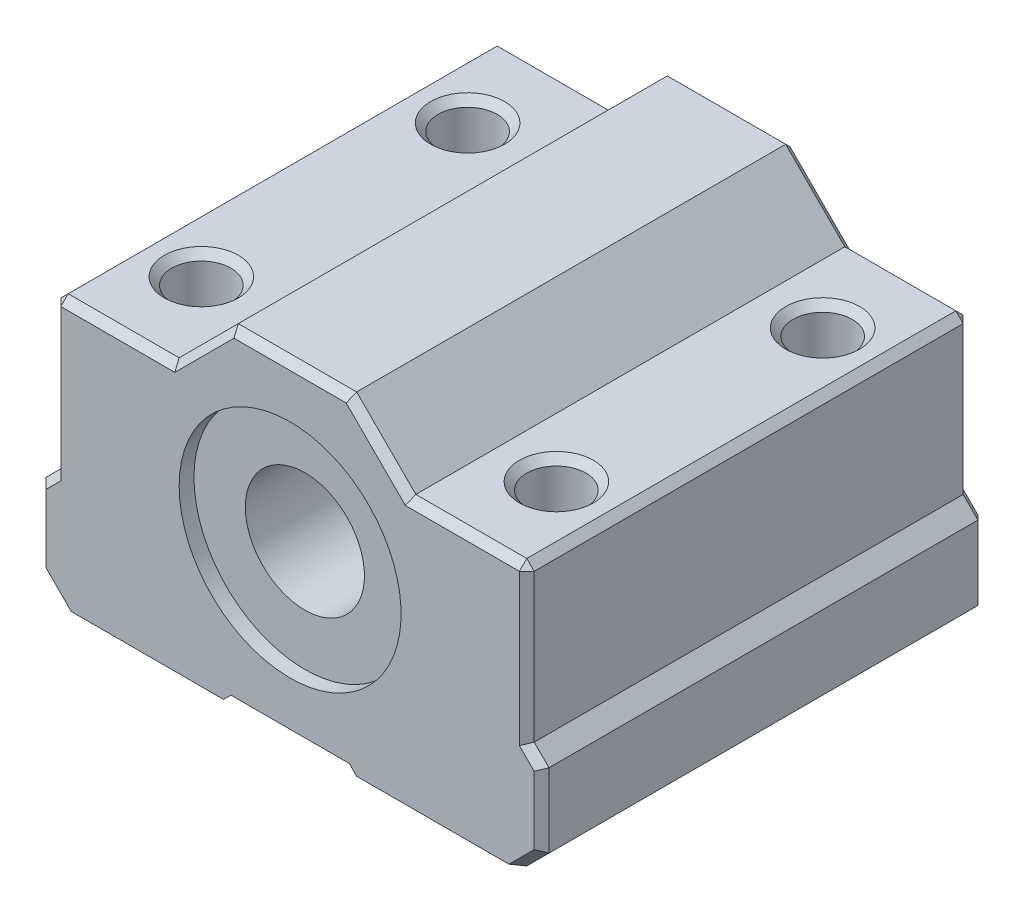
from build123d import *

# Parameters (mm, degrees)
ESBO_O1_W                      = 34
ESBO_O1_H                      = 30
RESSALTO_EXTRUS_O1_DEPTH       = 22
CORTE_EXTRUS_O1_DEPTH          = 31
CORTE_EXTRUS_O2_DEPTH          = 31
CORTE_EXTRUS_O3_DEPTH          = 31
CORTE_EXTRUS_O4_DEPTH          = 31
CORTE_EXTRUS_O5_DEPTH          = 31
FURO_DE_DI_METRO_4_0_4_1_D     = 4
FURO_DE_DI_METRO_4_0_4_1_DEPTH = 18
FURO_DE_DI_METRO_4_0_4_2_D     = 4
FURO_DE_DI_METRO_4_0_4_2_DEPTH = 22
CHANFRO1_SIZE                  = 1.5
CHANFRO2_SIZE                  = 0.500000009


with BuildPart() as part:
    # Esboço1 → Ressalto-extrusão1 (new body)
    with BuildSketch(Plane(origin=(0, 13.318571188, 0), x_dir=(1, 0, 0), z_dir=(0, 1, 0))):
        with Locations((0.093581821, -15)):
            Rectangle(ESBO_O1_W, ESBO_O1_H)
    extrude(amount=-RESSALTO_EXTRUS_O1_DEPTH)

    # Esboço2 → Corte-extrusão1 (cut, through all)
    with BuildSketch(Plane(origin=(0, 0, 0), x_dir=(-1, 0, 0), z_dir=(0, 0, -1))):
        Polygon((-17.093581821, -2.181428812), (-16.093581821, -1.181428812), (-16.093581821, 13.318571188), (-17.093581821, 13.318571188), align=None)
    extrude(amount=-CORTE_EXTRUS_O1_DEPTH, mode=Mode.SUBTRACT)

    # Esboço3 → Corte-extrusão2 (cut, through all)
    with BuildSketch(Plane(origin=(0, 0, 0), x_dir=(-1, 0, 0), z_dir=(0, 0, -1))):
        Polygon((-16.093581821, 13.318571188), (-16.093581821, 9.318571188), (-8.093581821, 9.318571188), (-4.093581821, 13.318571188), align=None)
    extrude(amount=-CORTE_EXTRUS_O2_DEPTH, mode=Mode.SUBTRACT)

    # Esboço4 → Corte-extrusão3 (cut, through all)
    with BuildSketch(Plane(origin=(0, 0, 0), x_dir=(-1, 0, 0), z_dir=(0, 0, -1))):
        Polygon((16.906418179, 13.318571188), (3.906418179, 13.318571188), (7.906418179, 9.318571188), (16.906418179, 9.318571188), align=None)
    extrude(amount=-CORTE_EXTRUS_O3_DEPTH, mode=Mode.SUBTRACT)

    # Esboço5 → Corte-extrusão4 (cut, through all)
    with BuildSketch(Plane(origin=(0, 0, 0), x_dir=(-1, 0, 0), z_dir=(0, 0, -1))):
        Polygon((15.906418179, 9.318571188), (15.906418179, -1.181428812), (16.906418179, -2.181428812), (16.906418179, 9.318571188), align=None)
    extrude(amount=-CORTE_EXTRUS_O4_DEPTH, mode=Mode.SUBTRACT)

    # Esboço6 → Corte-extrusão5 (cut, through all)
    with BuildSketch(Plane(origin=(0, 0, 0), x_dir=(-1, 0, 0), z_dir=(0, 0, -1))):
        Polygon((-4.593581821, -8.681428812), (4.406418179, -8.681428812), (3.906418179, -8.181428812), (-4.093581821, -8.181428812), align=None)
    extrude(amount=-CORTE_EXTRUS_O5_DEPTH, mode=Mode.SUBTRACT)

    # Esboço7 → Corte-Revolução1 (revolve, cut)
    with BuildSketch(Plane.XZ.offset(-2.318571188)):
        Polygon((7.593581821, 30), (0.093581821, 30), (0.093581821, 0), (7.593581821, 0), (7.593581821, 1), (4.118581821, 1), (4.118581821, 29), (7.593581821, 29), align=None)
    revolve(axis=Axis((0.093581821, 2.318571188, 30), (0, 0, -1)), mode=Mode.SUBTRACT)

    # Furo de diâmetro Ø4.0 (4)1
    with Locations(Plane(origin=(0, 9.318571188, 0), x_dir=(1, 0, 0), z_dir=(0, 1, 0))):
        with Locations((12.093581821, -24)):
            Hole(FURO_DE_DI_METRO_4_0_4_1_D / 2, depth=FURO_DE_DI_METRO_4_0_4_1_DEPTH)

    # Furo de diâmetro Ø4.0 (4)2
    with Locations(Plane(origin=(0, -8.681428812, 0), x_dir=(-1, 0, 0), z_dir=(0, -1, 0))):
        with Locations((11.906418179, -6), (11.906418179, -24), (-12.093581821, -6)):
            Hole(FURO_DE_DI_METRO_4_0_4_2_D / 2, depth=FURO_DE_DI_METRO_4_0_4_2_DEPTH)

    # Chanfro1
    chanfro1_edges = [part.edges().sort_by_distance(p)[0] for p in [
        (17.093581821, -8.681428812, 15),
        (-16.906418179, -8.681428812, 15),
    ]]
    chamfer(chanfro1_edges, length=CHANFRO1_SIZE)

    # Chanfro2
    chanfro2_edges = [part.edges().sort_by_distance(p)[0] for p in [
        (10.093581821, 9.318571188, 6),
        (10.093581821, -8.681428812, 6),
        (-13.906418179, 9.318571188, 24),
        (-13.906418179, -8.681428812, 24),
        (-13.906418179, 9.318571188, 6),
        (-13.906418179, -8.681428812, 6),
        (17.093581821, -4.681428812, 30),
        (17.093581821, -4.681428812, 0),
        (-16.906418179, -4.681428812, 0),
        (-16.156418179, -7.931428812, 0),
        (16.343581821, -7.931428812, 0),
        (-16.906418179, -4.681428812, 30),
        (-16.156418179, -7.931428812, 30),
        (16.343581821, -7.931428812, 30),
        (16.093581821, 4.068571188, 30),
        (16.593581821, -1.681428812, 30),
        (16.593581821, -1.681428812, 0),
        (16.093581821, 4.068571188, 0),
        (0.093581821, 13.318571188, 0),
        (6.093581821, 11.318571188, 30),
        (12.093581821, 9.318571188, 30),
        (16.093581821, 9.318571188, 15),
        (12.093581821, 9.318571188, 0),
        (6.093581821, 11.318571188, 0),
        (0.093581821, 13.318571188, 30),
        (-11.906418179, 9.318571188, 30),
        (-5.906418179, 11.318571188, 30),
        (-5.906418179, 11.318571188, 0),
        (-11.906418179, 9.318571188, 0),
        (-15.906418179, 9.318571188, 15),
        (-16.406418179, -1.681428812, 30),
        (-15.906418179, 4.068571188, 30),
        (-15.906418179, 4.068571188, 0),
        (-16.406418179, -1.681428812, 0),
        (14.093581821, 9.318571188, 24),
        (14.093581821, -8.681428812, 24),
    ]]
    chamfer(chanfro2_edges, length=CHANFRO2_SIZE)


solid = part.part
